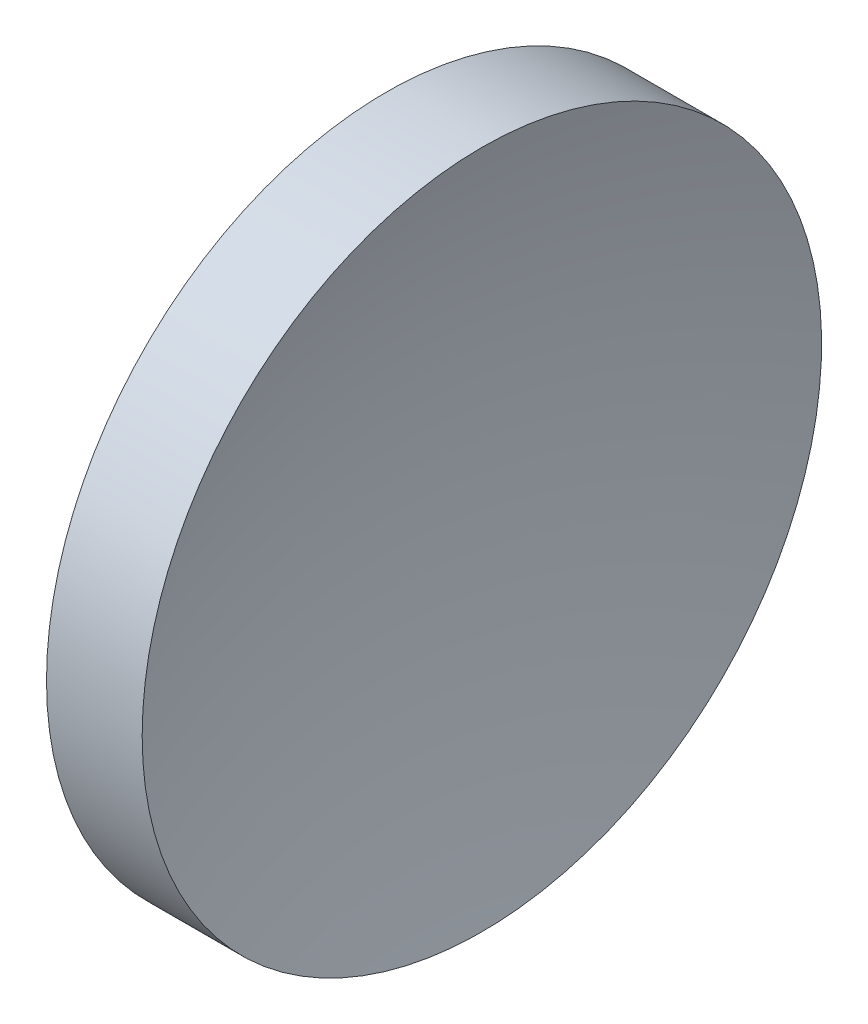
from build123d import *


with BuildPart() as part:
    # 草图1 → 旋转1 (revolve)
    with BuildSketch(Plane.XY):
        with BuildLine():
            Line((113.71989284, 65.155630457), (113.71989284, 87.655630457))
            Line((113.71989284, 87.655630457), (120.057008021, 87.655630457))
            ThreePointArc((120.057008021, 87.655630457), (117.55870991, 76.528694443), (116.71989284, 65.155630457))
            Line((116.71989284, 65.155630457), (113.71989284, 65.155630457))
        make_face()
    revolve(axis=Axis((105.621837124, 65.155630457, 0), (1, 0, 0)))


solid = part.part
